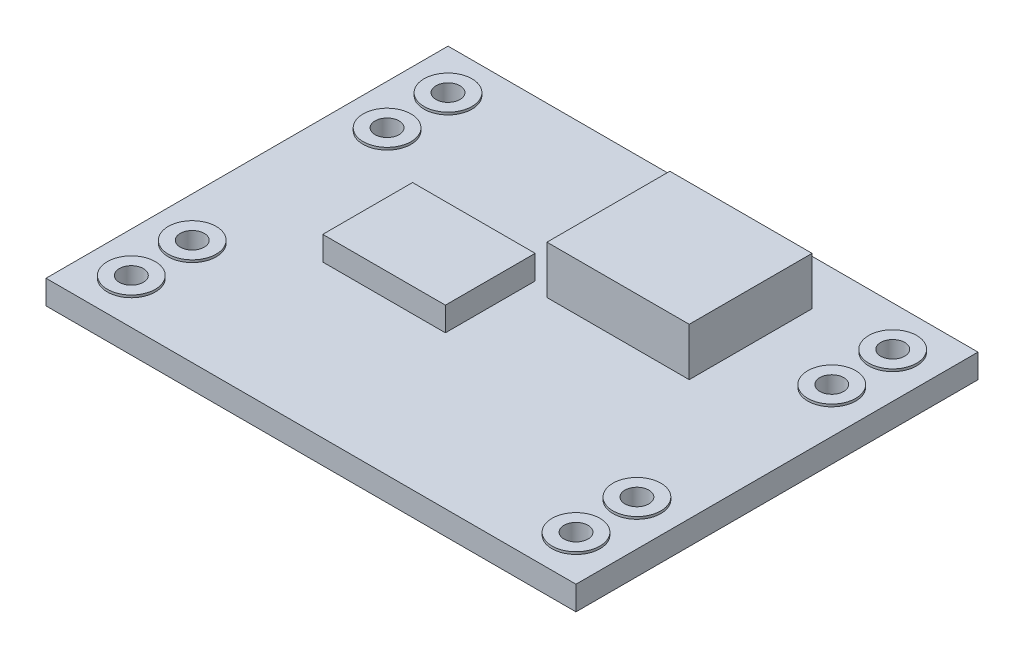
from build123d import *

# Parameters (mm, degrees)
SKETCH1_W           = 22.098
SKETCH1_H           = 16.764
BOSS_EXTRUDE1_DEPTH = 1
SKETCH2_R           = 1
BOSS_EXTRUDE2_DEPTH = 1.1
SKETCH4_R           = 0.5
CUT_EXTRUDE1_DEPTH  = 1.1
SKETCH5_W           = 5.931061502
SKETCH5_H           = 5.124055134
BOSS_EXTRUDE3_DEPTH = 2
SKETCH6_W           = 5.112840458
SKETCH6_H           = 3.742927716
BOSS_EXTRUDE4_DEPTH = 1


with BuildPart() as part:
    # Sketch1 → Boss-Extrude1 (new body)
    with BuildSketch(Plane(origin=(0, 0, 0), x_dir=(1, 0, 0), z_dir=(0, 1, 0))):
        with Locations((11.049, 8.382)):
            Rectangle(SKETCH1_W, SKETCH1_H)
    extrude(amount=BOSS_EXTRUDE1_DEPTH)

    # Sketch2 → Boss-Extrude2 (add)
    with BuildSketch(Plane.XZ):
        with Locations((1.778, -14.984)):
            Circle(SKETCH2_R)
        with Locations((20.32, -14.985792546)):
            Circle(SKETCH2_R)
        with Locations((1.778, -12.444)):
            Circle(SKETCH2_R)
        with Locations((20.32, -12.444)):
            Circle(SKETCH2_R)
        with Locations((1.778, -1.78)):
            Circle(SKETCH2_R)
        with Locations((1.778, -4.32)):
            Circle(SKETCH2_R)
        with Locations((20.32, -4.32)):
            Circle(SKETCH2_R)
        with Locations((20.32, -1.78)):
            Circle(SKETCH2_R)
    extrude(amount=-BOSS_EXTRUDE2_DEPTH)

    # Sketch4 → Cut-Extrude1 (cut)
    with BuildSketch(Plane(origin=(0, 1.1, 0), x_dir=(1, 0, 0), z_dir=(0, 1, 0))):
        with Locations((1.778, 14.984)):
            Circle(SKETCH4_R)
        with Locations((1.778, 12.444)):
            Circle(SKETCH4_R)
        with Locations((1.778, 4.32)):
            Circle(SKETCH4_R)
        with Locations((1.778, 1.78)):
            Circle(SKETCH4_R)
        with Locations((20.32, 14.985792546)):
            Circle(SKETCH4_R)
        with Locations((20.32, 12.444)):
            Circle(SKETCH4_R)
        with Locations((20.32, 4.32)):
            Circle(SKETCH4_R)
        with Locations((20.32, 1.78)):
            Circle(SKETCH4_R)
    extrude(amount=-CUT_EXTRUDE1_DEPTH, mode=Mode.SUBTRACT)

    # Sketch5 → Boss-Extrude3 (add)
    with BuildSketch(Plane(origin=(0, 1, 0), x_dir=(1, 0, 0), z_dir=(0, 1, 0))):
        with Locations((14.107616891, 12.30880124)):
            Rectangle(SKETCH5_W, SKETCH5_H)
    extrude(amount=BOSS_EXTRUDE3_DEPTH)

    # Sketch6 → Boss-Extrude4 (add)
    with BuildSketch(Plane(origin=(0, 1, 0), x_dir=(1, 0, 0), z_dir=(0, 1, 0))):
        with Locations((7.742395479, 8.226436285)):
            Rectangle(SKETCH6_W, SKETCH6_H)
    extrude(amount=BOSS_EXTRUDE4_DEPTH)


solid = part.part
